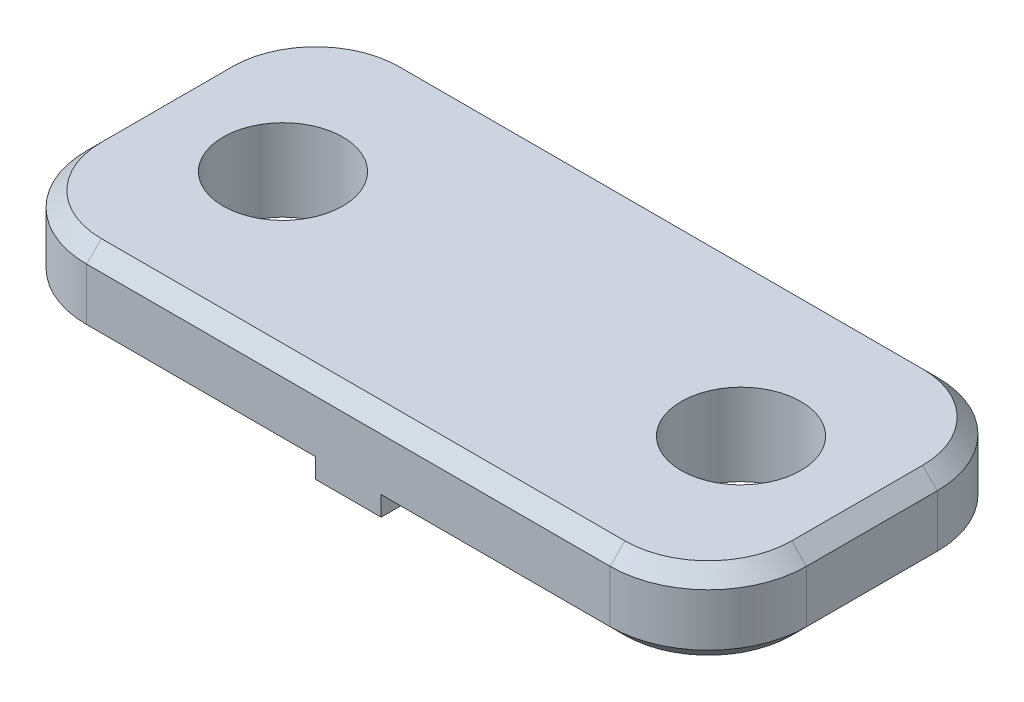
from build123d import *

# Parameters (mm, degrees)
SKETCH1_W             = 22
SKETCH1_H             = 10
BOSS_EXTRUDE1_DEPTH   = 2.5
F_6_CLEARANCE_HOLE1_D = 3.6576
SKETCH4_W             = 2
SKETCH4_H             = 10
BOSS_EXTRUDE2_DEPTH   = 0.15
FILLET1_R             = 3
CHAMFER1_SIZE         = 0.45


with BuildPart() as part:
    # Sketch1 → Boss-Extrude1 (new body)
    with BuildSketch(Plane(origin=(0, 0, 0), x_dir=(1, 0, 0), z_dir=(0, 1, 0))):
        Rectangle(SKETCH1_W, SKETCH1_H)
    extrude(amount=BOSS_EXTRUDE1_DEPTH)

    # #6 Clearance Hole1 (through all)
    with Locations(Plane(origin=(0, 2.5, 0), x_dir=(1, 0, 0), z_dir=(0, 1, 0))):
        with Locations((7, 0), (-7, 0)):
            Hole(F_6_CLEARANCE_HOLE1_D / 2)

    # Sketch4 → Boss-Extrude2 (add)
    with BuildSketch(Plane.XZ):
        Rectangle(SKETCH4_W, SKETCH4_H)
    extrude(amount=BOSS_EXTRUDE2_DEPTH)

    # Fillet1
    fillet1_edges = [part.edges().sort_by_distance(p)[0] for p in [
        (11, 1.25, 5),
        (-11, 1.25, 5),
        (-11, 1.25, -5),
        (11, 1.25, -5),
    ]]
    fillet(fillet1_edges, radius=FILLET1_R)

    # Chamfer1
    chamfer1_edges = [part.edges().sort_by_distance(p)[0] for p in [
        (4.5, 0, 5),
        (-4.5, 0, -5),
        (11, 0, 0),
        (11, 2.5, 0),
        (4.5, 0, -5),
        (10.121320344, 0, -4.121320344),
        (10.121320344, 0, 4.121320344),
        (-4.5, 0, 5),
        (0, 2.5, 5),
        (0, 2.5, -5),
        (-11, 2.5, 0),
        (-10.121320344, 2.5, 4.121320344),
        (-10.121320344, 2.5, -4.121320344),
        (10.121320344, 2.5, -4.121320344),
        (10.121320344, 2.5, 4.121320344),
        (-11, 0, 0),
        (-10.121320344, 0, 4.121320344),
        (-10.121320344, 0, -4.121320344),
    ]]
    chamfer(chamfer1_edges, length=CHAMFER1_SIZE)


solid = part.part
